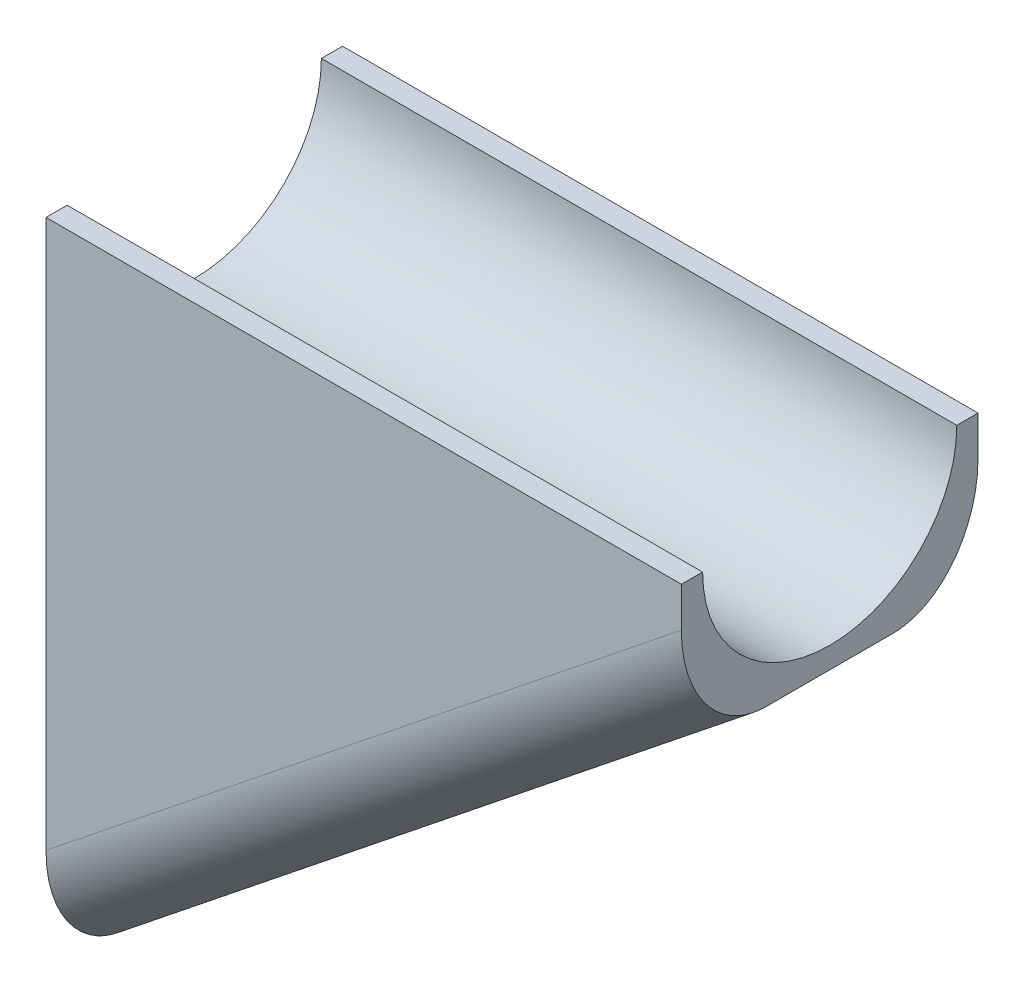
from build123d import *

# Parameters (mm, degrees)
BOSS_EXTRUDE1_DEPTH     = 7
SKETCH3_W               = 15
SKETCH3_H               = 7
BOSS_EXTRUDE2_DEPTH     = 3.5
CUT_EXTRUDE1_DEPTH      = 1
CUT_EXTRUDE1_DEPTH_BACK = 16
FILLET1_R               = 2


with BuildPart() as part:
    # Sketch1 → Boss-Extrude1 (new body)
    with BuildSketch(Plane.XY):
        Polygon((-7.5, -6), (7.5, 6), (-7.5, 6), align=None)
    extrude(amount=BOSS_EXTRUDE1_DEPTH)

    # Sketch3 → Boss-Extrude2 (add)
    with BuildSketch(Plane(origin=(0, 6, 0), x_dir=(1, 0, 0), z_dir=(0, 1, 0))):
        with Locations((0, -3.5)):
            Rectangle(SKETCH3_W, SKETCH3_H)
    extrude(amount=BOSS_EXTRUDE2_DEPTH)

    # Sketch4 → Cut-Extrude1 (cut, two sides)
    with BuildSketch(Plane(origin=(7.5, 0, 0), x_dir=(0, 0, -1), z_dir=(1, 0, 0))) as cut_extrude1_sk:
        with BuildLine():
            Line((-6.5, 53.115472628), (-6.5, 9.5))
            ThreePointArc((-6.5, 9.5), (-3.5, 6.5), (-0.5, 9.5))
            Line((-0.5, 9.5), (-0.5, 53.115472628))
            Line((-0.5, 53.115472628), (-0.5, 140.346417884))
            Line((-0.5, 140.346417884), (-6.5, 140.346417884))
            Line((-6.5, 140.346417884), (-6.5, 53.115472628))
        make_face()
    extrude(amount=CUT_EXTRUDE1_DEPTH, mode=Mode.SUBTRACT)
    extrude(cut_extrude1_sk.sketch, amount=-CUT_EXTRUDE1_DEPTH_BACK, mode=Mode.SUBTRACT)

    # Fillet1
    fillet1_edges = [part.edges().sort_by_distance(p)[0] for p in [
        (0, 0, 0),
        (0, 0, 7),
    ]]
    fillet(fillet1_edges, radius=FILLET1_R)


solid = part.part
